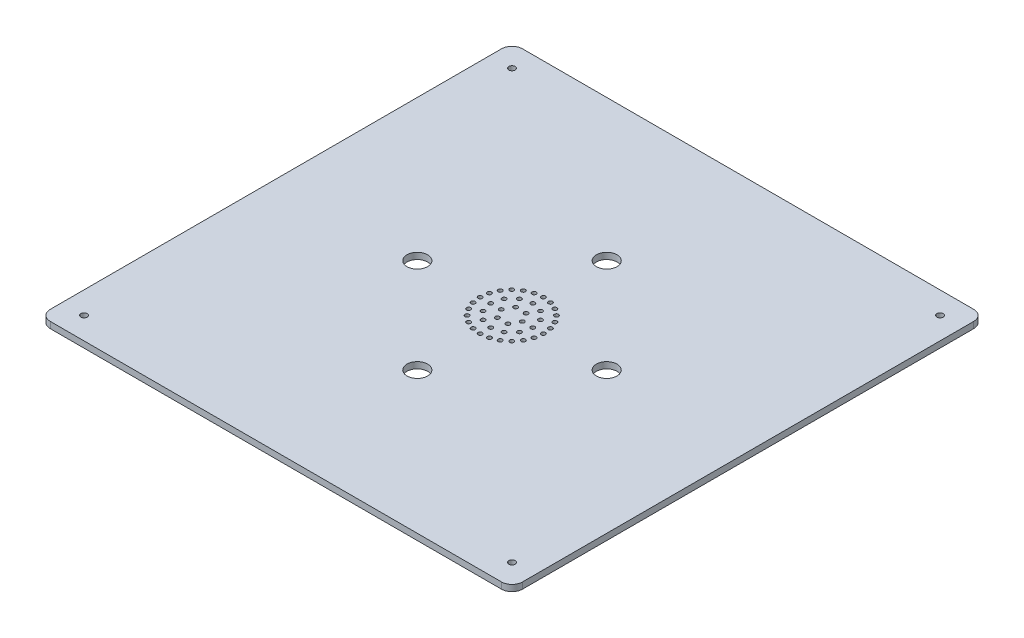
from build123d import *

# Parameters (mm, degrees)
SKETCH1_W           = 224.4
SKETCH1_H           = 224.4
SKETCH1_R           = 1.5
BOSS_EXTRUDE1_DEPTH = 3
FILLET1_R           = 5
SKETCH2_R           = 1
CUT_EXTRUDE1_DEPTH  = 4
SKETCH4_R           = 4.9
CUT_EXTRUDE2_DEPTH  = 4


with BuildPart() as part:
    # Sketch1 → Boss-Extrude1 (new body)
    with BuildSketch(Plane(origin=(0, 0, 0), x_dir=(1, 0, 0), z_dir=(0, 1, 0))):
        with Locations((112.2, 112.2)):
            Rectangle(SKETCH1_W, SKETCH1_H)
        with Locations((213.9, 10.5)):
            Circle(SKETCH1_R, mode=Mode.SUBTRACT)
        with Locations((213.9, 213.9)):
            Circle(SKETCH1_R, mode=Mode.SUBTRACT)
        with Locations((10.5, 10.5)):
            Circle(SKETCH1_R, mode=Mode.SUBTRACT)
        with Locations((10.5, 213.9)):
            Circle(SKETCH1_R, mode=Mode.SUBTRACT)
    extrude(amount=BOSS_EXTRUDE1_DEPTH)

    # Fillet1
    fillet1_edges = [part.edges().sort_by_distance(p)[0] for p in [
        (0, 1.5, -224.4),
        (224.4, 1.5, -224.4),
        (224.4, 1.5, 0),
        (0, 1.5, 0),
    ]]
    fillet(fillet1_edges, radius=FILLET1_R)

    # Sketch2 → Cut-Extrude1 (cut, through all)
    with BuildSketch(Plane(origin=(0, 3, 0), x_dir=(1, 0, 0), z_dir=(0, 1, 0))):
        with Locations((117.180175368, 112.100128542)):
            Circle(SKETCH2_R)
        with Locations((122.180175368, 112.100128542)):
            Circle(SKETCH2_R)
        with Locations((127.180175368, 112.100128542)):
            Circle(SKETCH2_R)
        with Locations((114.680175368, 107.770001523)):
            Circle(SKETCH2_R)
        with Locations((109.680175368, 107.770001523)):
            Circle(SKETCH2_R)
        with Locations((107.180175368, 112.100128542)):
            Circle(SKETCH2_R)
        with Locations((109.680175368, 116.430255561)):
            Circle(SKETCH2_R)
        with Locations((114.680175368, 116.430255561)):
            Circle(SKETCH2_R)
        with Locations((120.840429406, 107.100128542)):
            Circle(SKETCH2_R)
        with Locations((117.180175368, 103.439874505)):
            Circle(SKETCH2_R)
        with Locations((112.180175368, 102.100128542)):
            Circle(SKETCH2_R)
        with Locations((107.180175368, 103.439874505)):
            Circle(SKETCH2_R)
        with Locations((103.51992133, 107.100128542)):
            Circle(SKETCH2_R)
        with Locations((102.180175368, 112.100128542)):
            Circle(SKETCH2_R)
        with Locations((103.51992133, 117.100128542)):
            Circle(SKETCH2_R)
        with Locations((107.180175368, 120.76038258)):
            Circle(SKETCH2_R)
        with Locations((112.180175368, 122.100128542)):
            Circle(SKETCH2_R)
        with Locations((117.180175368, 120.76038258)):
            Circle(SKETCH2_R)
        with Locations((120.840429406, 117.100128542)):
            Circle(SKETCH2_R)
        with Locations((126.669062762, 108.217842866)):
            Circle(SKETCH2_R)
        with Locations((125.170556425, 104.600128542)):
            Circle(SKETCH2_R)
        with Locations((122.786777086, 101.493526825)):
            Circle(SKETCH2_R)
        with Locations((119.680175368, 99.109747486)):
            Circle(SKETCH2_R)
        with Locations((116.062461045, 97.611241148)):
            Circle(SKETCH2_R)
        with Locations((112.180175368, 97.100128542)):
            Circle(SKETCH2_R)
        with Locations((108.297889692, 97.611241148)):
            Circle(SKETCH2_R)
        with Locations((104.680175368, 99.109747486)):
            Circle(SKETCH2_R)
        with Locations((101.57357365, 101.493526825)):
            Circle(SKETCH2_R)
        with Locations((99.189794311, 104.600128542)):
            Circle(SKETCH2_R)
        with Locations((97.691287974, 108.217842866)):
            Circle(SKETCH2_R)
        with Locations((97.180175368, 112.100128542)):
            Circle(SKETCH2_R)
        with Locations((97.691287974, 115.982414219)):
            Circle(SKETCH2_R)
        with Locations((99.189794311, 119.600128542)):
            Circle(SKETCH2_R)
        with Locations((101.57357365, 122.70673026)):
            Circle(SKETCH2_R)
        with Locations((104.680175368, 125.090509599)):
            Circle(SKETCH2_R)
        with Locations((108.297889692, 126.589015937)):
            Circle(SKETCH2_R)
        with Locations((112.180175368, 127.100128542)):
            Circle(SKETCH2_R)
        with Locations((116.062461045, 126.589015937)):
            Circle(SKETCH2_R)
        with Locations((119.680175368, 125.090509599)):
            Circle(SKETCH2_R)
        with Locations((122.786777086, 122.70673026)):
            Circle(SKETCH2_R)
        with Locations((125.170556425, 119.600128542)):
            Circle(SKETCH2_R)
        with Locations((126.669062762, 115.982414219)):
            Circle(SKETCH2_R)
    extrude(amount=-CUT_EXTRUDE1_DEPTH, mode=Mode.SUBTRACT)

    # Sketch4 → Cut-Extrude2 (cut, through all)
    with BuildSketch(Plane(origin=(0, 3, 0), x_dir=(1, 0, 0), z_dir=(0, 1, 0))):
        with Locations((112.2, 157.2)):
            Circle(SKETCH4_R)
        with Locations((157.2, 112.2)):
            Circle(SKETCH4_R)
        with Locations((112.2, 67.2)):
            Circle(SKETCH4_R)
        with Locations((67.2, 112.2)):
            Circle(SKETCH4_R)
    extrude(amount=-CUT_EXTRUDE2_DEPTH, mode=Mode.SUBTRACT)


solid = part.part
